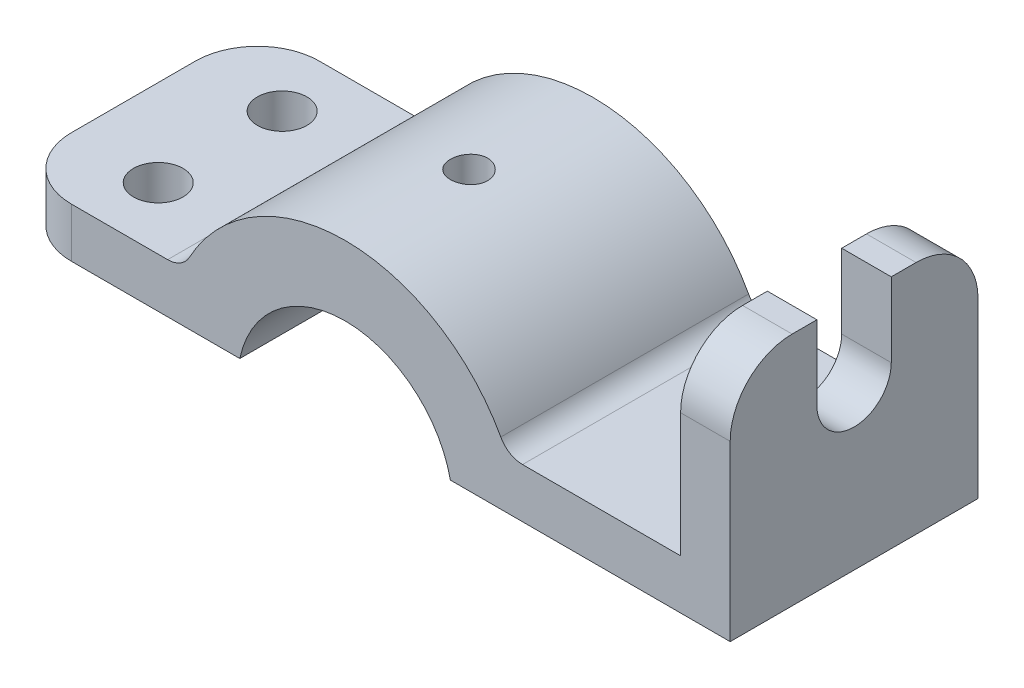
from build123d import *

# Parameters (mm, degrees)
ESTRUSIONE_ESTRUSIONE1_DEPTH = 10
RACCORDO1_R                  = 5
RACCORDO2_R                  = 5
RACCORDO3_R                  = 2
SCHIZZO3_R                   = 2
TAGLIO_ESTRUSIONE1_DEPTH     = 20
SCHIZZO5_R                   = 1.5
TAGLIO_ESTRUSIONE2_DEPTH     = 20
TAGLIO_ESTRUSIONE3_DEPTH     = 20


with BuildPart() as part:
    # Schizzo2 → Estrusione-Estrusione1 (new body, symmetric)
    with BuildSketch(Plane.XY):
        with BuildLine():
            Line((-27.079304388, 0), (-27.079304388, 4))
            Line((-27.079304388, 4), (-13.079304388, 4))
            ThreePointArc((-13.079304388, 4), (0, 12.506273841), (13.079304388, 4))
            Line((13.079304388, 4), (27.079304388, 4))
            Line((27.079304388, 4), (27.079304388, 19))
            Line((27.079304388, 19), (31.079304388, 19))
            Line((31.079304388, 19), (31.079304388, 0))
            Line((31.079304388, 0), (8.496839078, 0))
            ThreePointArc((8.496839078, 0), (0, 6.88360126), (-8.496839078, 0))
            Line((-8.496839078, 0), (-27.079304388, 0))
        make_face()
    extrude(amount=ESTRUSIONE_ESTRUSIONE1_DEPTH, both=True)

    # Raccordo1
    raccordo1_edges = [part.edges().sort_by_distance(p)[0] for p in [
        (29.079304388, 19, -10),
        (29.079304388, 19, 10),
    ]]
    fillet(raccordo1_edges, radius=RACCORDO1_R)

    # Raccordo2
    raccordo2_edges = [part.edges().sort_by_distance(p)[0] for p in [
        (-27.079304388, 2, -10),
        (-27.079304388, 2, 10),
    ]]
    fillet(raccordo2_edges, radius=RACCORDO2_R)

    # Raccordo3
    raccordo3_edges = [part.edges().sort_by_distance(p)[0] for p in [
        (-13.079304388, 4, 0),
        (13.079304388, 4, 0),
    ]]
    fillet(raccordo3_edges, radius=RACCORDO3_R)

    # Schizzo3 → Taglio-Estrusione1 (cut)
    with BuildSketch(Plane(origin=(0, 4, 0), x_dir=(1, 0, 0), z_dir=(0, 1, 0))):
        with Locations((-20.079304388, 5)):
            Circle(SCHIZZO3_R)
    taglio_estrusione1 = extrude(amount=-TAGLIO_ESTRUSIONE1_DEPTH, mode=Mode.SUBTRACT)

    # Specchia1: Taglio-Estrusione1 across plane
    add(taglio_estrusione1.mirror(Plane.XY), mode=Mode.SUBTRACT)

    # Schizzo5 → Taglio-Estrusione2 (cut)
    with BuildSketch(Plane(origin=(0, 0, 0), x_dir=(1, 0, 0), z_dir=(0, 1, 0))):
        Circle(SCHIZZO5_R)
    extrude(amount=TAGLIO_ESTRUSIONE2_DEPTH, mode=Mode.SUBTRACT)

    # Schizzo7 → Taglio-Estrusione3 (cut)
    with BuildSketch(Plane(origin=(31.079304388, 0, 0), x_dir=(0, 0, -1), z_dir=(1, 0, 0))):
        with BuildLine():
            Line((-3, 19), (-3, 13))
            ThreePointArc((-3, 13), (0, 10), (3, 13))
            Line((3, 13), (3, 19))
            Line((3, 19), (-3, 19))
        make_face()
    extrude(amount=-TAGLIO_ESTRUSIONE3_DEPTH, mode=Mode.SUBTRACT)


solid = part.part
